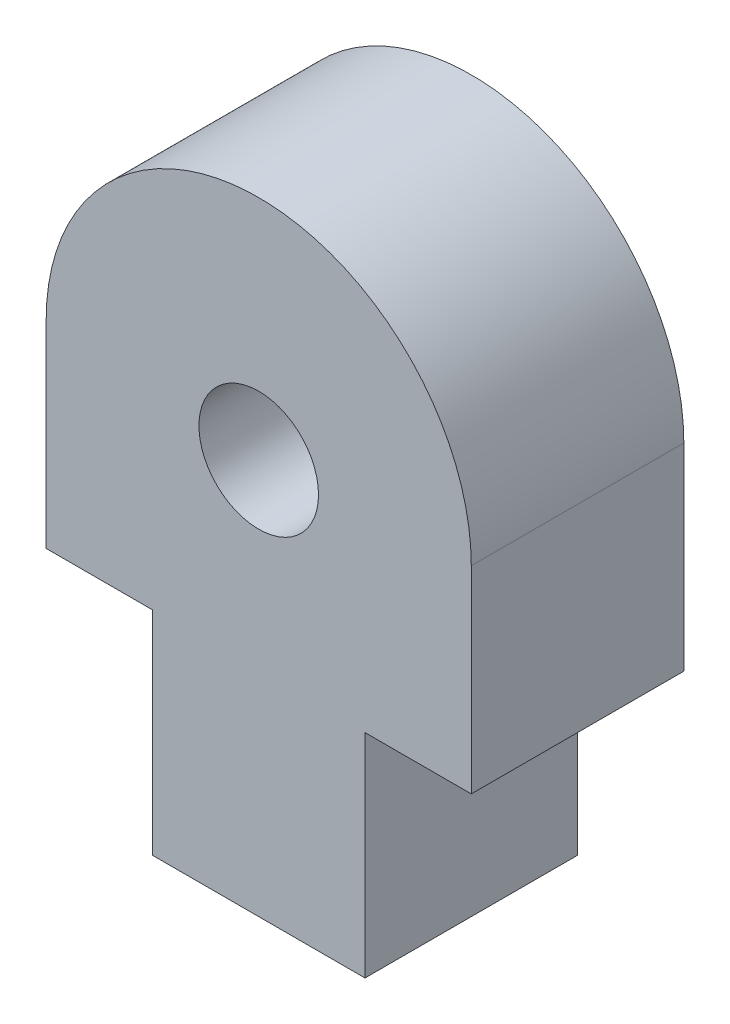
from build123d import *

# Parameters (mm, degrees)
BOSS_EXTRUDE1_DEPTH             = 6.35
F_9_64_0_14063_DIAMETER_HOLE1_D = 3.572002


with BuildPart() as part:
    # Sketch1 → Boss-Extrude1 (new body)
    with BuildSketch(Plane.XY):
        with BuildLine():
            Line((-6.35, 6.35), (-9.525, 6.35))
            Line((-9.525, 6.35), (-9.525, 12.25423))
            ThreePointArc((-9.525, 12.25423), (-3.175, 18.60423), (3.175, 12.25423))
            Line((3.175, 12.25423), (3.175, 6.35))
            Line((3.175, 6.35), (0, 6.35))
            Line((0, 6.35), (0, 0))
            Line((0, 0), (-6.35, 0))
            Line((-6.35, 0), (-6.35, 6.35))
        make_face()
    extrude(amount=BOSS_EXTRUDE1_DEPTH)

    # 9/64 (0.14063) Diameter Hole1 (through all)
    with Locations(Plane.XY.offset(6.35)):
        with Locations((-3.175, 11.80846)):
            Hole(F_9_64_0_14063_DIAMETER_HOLE1_D / 2)


solid = part.part
